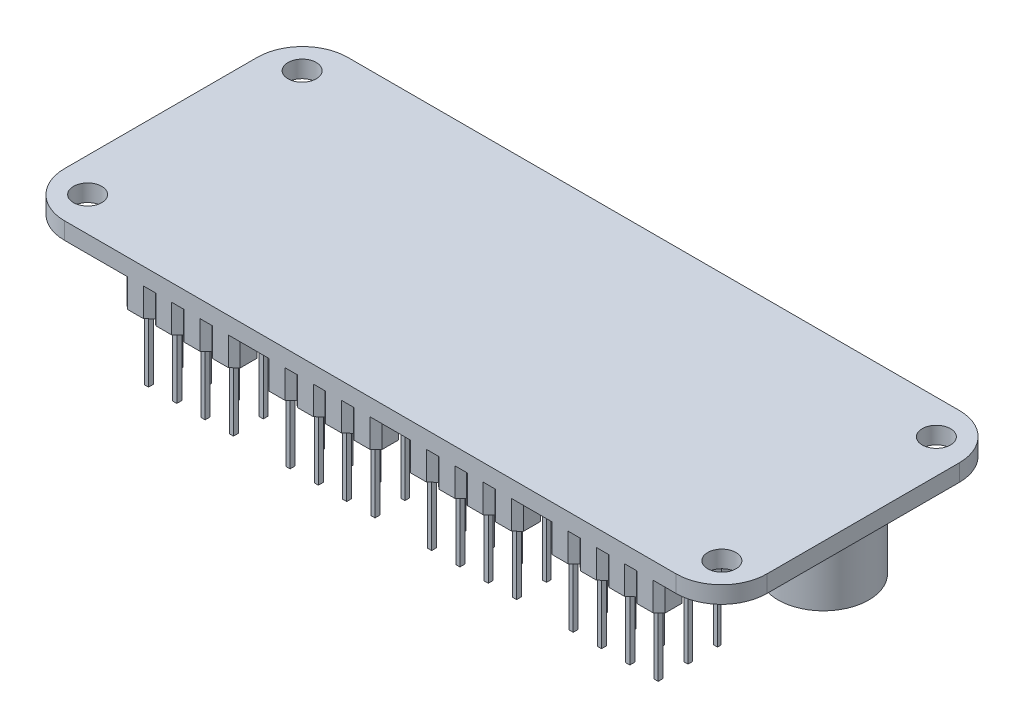
from build123d import *

# Parameters (mm, degrees)
CROQUIS1_W                  = 62
CROQUIS1_H                  = 25
SALIENTE_EXTRUIR1_DEPTH     = 1.5
REDONDEO1_R                 = 4
CROQUIS2_R                  = 1.25
CORTAR_EXTRUIR1_DEPTH       = 10
CROQUIS3_R                  = 4
SALIENTE_EXTRUIR2_DEPTH     = 13
SALIENTE_EXTRUIR3_DEPTH     = 2.5
CROQUIS5_W                  = 0.360808051
CROQUIS5_H                  = 0.305625598
CROQUIS5_H_2                = 0.406989353
CROQUIS5_H_3                = 0.438823002
SALIENTE_EXTRUIR4_DEPTH     = 6
MATRIZL1_COUNT              = 4
MATRIZL1_PITCH              = 2.5
MATRIZL2_COUNT              = 4
MATRIZL2_PITCH              = 12.5
MATRIZL2_COPY_1_DEPTH       = 2.5
MATRIZL2_COPY_2_DEPTH       = 2.5
MATRIZL2_COPY_3_DEPTH       = 2.5
MATRIZL2_COPY_4_DEPTH       = 2.5
MATRIZL2_COPY_5_DEPTH       = 2.5
MATRIZL2_COPY_6_DEPTH       = 2.5
MATRIZL2_COPY_7_DEPTH       = 2.5
MATRIZL2_COPY_8_DEPTH       = 2.5
MATRIZL2_COPY_9_DEPTH       = 2.5
MATRIZL2_COPY_10_SKETCH_W   = 0.360808051
MATRIZL2_COPY_10_SKETCH_H   = 0.305625598
MATRIZL2_COPY_10_SKETCH_H_2 = 0.406989353
MATRIZL2_COPY_10_SKETCH_H_3 = 0.438823002
MATRIZL2_COPY_10_DEPTH      = 6
MATRIZL2_COPY_11_SKETCH_W   = 0.360808051
MATRIZL2_COPY_11_SKETCH_H   = 0.305625598
MATRIZL2_COPY_11_SKETCH_H_2 = 0.406989353
MATRIZL2_COPY_11_SKETCH_H_3 = 0.438823002
MATRIZL2_COPY_11_DEPTH      = 6
MATRIZL2_COPY_12_SKETCH_W   = 0.360808051
MATRIZL2_COPY_12_SKETCH_H   = 0.305625598
MATRIZL2_COPY_12_SKETCH_H_2 = 0.406989353
MATRIZL2_COPY_12_SKETCH_H_3 = 0.438823002
MATRIZL2_COPY_12_DEPTH      = 6
MATRIZL2_COPY_13_SKETCH_W   = 0.360808051
MATRIZL2_COPY_13_SKETCH_H   = 0.305625598
MATRIZL2_COPY_13_SKETCH_H_2 = 0.406989353
MATRIZL2_COPY_13_SKETCH_H_3 = 0.438823002
MATRIZL2_COPY_13_DEPTH      = 6
MATRIZL2_COPY_14_SKETCH_W   = 0.360808051
MATRIZL2_COPY_14_SKETCH_H   = 0.305625598
MATRIZL2_COPY_14_SKETCH_H_2 = 0.406989353
MATRIZL2_COPY_14_SKETCH_H_3 = 0.438823002
MATRIZL2_COPY_14_DEPTH      = 6
MATRIZL2_COPY_15_SKETCH_W   = 0.360808051
MATRIZL2_COPY_15_SKETCH_H   = 0.305625598
MATRIZL2_COPY_15_SKETCH_H_2 = 0.406989353
MATRIZL2_COPY_15_SKETCH_H_3 = 0.438823002
MATRIZL2_COPY_15_DEPTH      = 6
MATRIZL2_COPY_16_SKETCH_W   = 0.360808051
MATRIZL2_COPY_16_SKETCH_H   = 0.305625598
MATRIZL2_COPY_16_SKETCH_H_2 = 0.406989353
MATRIZL2_COPY_16_SKETCH_H_3 = 0.438823002
MATRIZL2_COPY_16_DEPTH      = 6
MATRIZL2_COPY_17_SKETCH_W   = 0.360808051
MATRIZL2_COPY_17_SKETCH_H   = 0.305625598
MATRIZL2_COPY_17_SKETCH_H_2 = 0.406989353
MATRIZL2_COPY_17_SKETCH_H_3 = 0.438823002
MATRIZL2_COPY_17_DEPTH      = 6
MATRIZL2_COPY_18_SKETCH_W   = 0.360808051
MATRIZL2_COPY_18_SKETCH_H   = 0.305625598
MATRIZL2_COPY_18_SKETCH_H_2 = 0.406989353
MATRIZL2_COPY_18_SKETCH_H_3 = 0.438823002
MATRIZL2_COPY_18_DEPTH      = 6


with BuildPart() as part:
    # Croquis1 → Saliente-Extruir1 (new body)
    with BuildSketch(Plane(origin=(0, 0, 0), x_dir=(1, 0, 0), z_dir=(0, 1, 0))):
        Rectangle(CROQUIS1_W, CROQUIS1_H)
    extrude(amount=SALIENTE_EXTRUIR1_DEPTH)

    # Redondeo1
    redondeo1_edges = [part.edges().sort_by_distance(p)[0] for p in [
        (31, 0.75, 12.5),
        (-31, 0.75, 12.5),
        (-31, 0.75, -12.5),
        (31, 0.75, -12.5),
    ]]
    fillet(redondeo1_edges, radius=REDONDEO1_R)

    # Croquis2 → Cortar-Extruir1 (cut)
    with BuildSketch(Plane(origin=(0, 1.5, 0), x_dir=(1, 0, 0), z_dir=(0, 1, 0))):
        with Locations((-28, 9.47)):
            Circle(CROQUIS2_R)
        with Locations((28, 9.47)):
            Circle(CROQUIS2_R)
        with Locations((28, -9.47)):
            Circle(CROQUIS2_R)
        with Locations((-28, -9.47)):
            Circle(CROQUIS2_R)
    extrude(amount=-CORTAR_EXTRUIR1_DEPTH, mode=Mode.SUBTRACT)

    # Croquis3 → Saliente-Extruir2 (add)
    with BuildSketch(Plane.XZ):
        with Locations((19, -8.5)):
            Circle(CROQUIS3_R)
    extrude(amount=SALIENTE_EXTRUIR2_DEPTH)

    # Croquis4 → Saliente-Extruir3 (add)
    with BuildSketch(Plane.XZ):
        Polygon((24.951236273, 5), (23.548763727, 5), (23, 5.501296545), (23, 6.998703455), (23.548763727, 7.5), (23, 8.001296545), (23, 9.498703455), (23.548763727, 10), (23, 10.501296545), (23, 11.998703455), (23.548763727, 12.5), (24.951236273, 12.5), (25.5, 11.998703455), (25.5, 10.501296545), (24.951236273, 10), (25.5, 9.498703455), (25.5, 8.001296545), (24.951236273, 7.5), (25.5, 6.998703455), (25.5, 5.501296545), align=None)
    saliente_extruir3 = extrude(amount=SALIENTE_EXTRUIR3_DEPTH)

    # Croquis5 → Saliente-Extruir4 (add)
    with BuildSketch(Plane.XZ.offset(2.5)):
        with Locations((24.238999637, 6.119725435)):
            Rectangle(CROQUIS5_W, CROQUIS5_H)
        with Locations((24.238999637, 8.674638073)):
            Rectangle(CROQUIS5_W, CROQUIS5_H_2)
        with Locations((24.238999637, 11.296149412)):
            Rectangle(CROQUIS5_W, CROQUIS5_H_3)
    saliente_extruir4 = extrude(amount=SALIENTE_EXTRUIR4_DEPTH)

    # MatrizL1: Saliente-Extruir3, Saliente-Extruir4 ×4
    with Locations(*[(-i * MATRIZL1_PITCH, 0, 0) for i in range(1, MATRIZL1_COUNT)]):
        add(saliente_extruir3)
        add(saliente_extruir4)

    # MatrizL2: Saliente-Extruir3, Saliente-Extruir4 ×4
    with Locations(*[(-i * MATRIZL2_PITCH, 0, 0) for i in range(1, MATRIZL2_COUNT)]):
        add(saliente_extruir3)
        add(saliente_extruir4)

    # MatrizL2 copy 1 sketch → MatrizL2 copy 1 (add)
    with BuildSketch(Plane(origin=(-15, 0, 0), x_dir=(1, 0, 0), z_dir=(0, -1, 0))):
        Polygon((24.951236273, 5), (23.548763727, 5), (23, 5.501296545), (23, 6.998703455), (23.548763727, 7.5), (23, 8.001296545), (23, 9.498703455), (23.548763727, 10), (23, 10.501296545), (23, 11.998703455), (23.548763727, 12.5), (24.951236273, 12.5), (25.5, 11.998703455), (25.5, 10.501296545), (24.951236273, 10), (25.5, 9.498703455), (25.5, 8.001296545), (24.951236273, 7.5), (25.5, 6.998703455), (25.5, 5.501296545), align=None)
    extrude(amount=MATRIZL2_COPY_1_DEPTH)

    # MatrizL2 copy 2 sketch → MatrizL2 copy 2 (add)
    with BuildSketch(Plane(origin=(-27.5, 0, 0), x_dir=(1, 0, 0), z_dir=(0, -1, 0))):
        Polygon((24.951236273, 5), (23.548763727, 5), (23, 5.501296545), (23, 6.998703455), (23.548763727, 7.5), (23, 8.001296545), (23, 9.498703455), (23.548763727, 10), (23, 10.501296545), (23, 11.998703455), (23.548763727, 12.5), (24.951236273, 12.5), (25.5, 11.998703455), (25.5, 10.501296545), (24.951236273, 10), (25.5, 9.498703455), (25.5, 8.001296545), (24.951236273, 7.5), (25.5, 6.998703455), (25.5, 5.501296545), align=None)
    extrude(amount=MATRIZL2_COPY_2_DEPTH)

    # MatrizL2 copy 3 sketch → MatrizL2 copy 3 (add)
    with BuildSketch(Plane(origin=(-40, 0, 0), x_dir=(1, 0, 0), z_dir=(0, -1, 0))):
        Polygon((24.951236273, 5), (23.548763727, 5), (23, 5.501296545), (23, 6.998703455), (23.548763727, 7.5), (23, 8.001296545), (23, 9.498703455), (23.548763727, 10), (23, 10.501296545), (23, 11.998703455), (23.548763727, 12.5), (24.951236273, 12.5), (25.5, 11.998703455), (25.5, 10.501296545), (24.951236273, 10), (25.5, 9.498703455), (25.5, 8.001296545), (24.951236273, 7.5), (25.5, 6.998703455), (25.5, 5.501296545), align=None)
    extrude(amount=MATRIZL2_COPY_3_DEPTH)

    # MatrizL2 copy 4 sketch → MatrizL2 copy 4 (add)
    with BuildSketch(Plane(origin=(-17.5, 0, 0), x_dir=(1, 0, 0), z_dir=(0, -1, 0))):
        Polygon((24.951236273, 5), (23.548763727, 5), (23, 5.501296545), (23, 6.998703455), (23.548763727, 7.5), (23, 8.001296545), (23, 9.498703455), (23.548763727, 10), (23, 10.501296545), (23, 11.998703455), (23.548763727, 12.5), (24.951236273, 12.5), (25.5, 11.998703455), (25.5, 10.501296545), (24.951236273, 10), (25.5, 9.498703455), (25.5, 8.001296545), (24.951236273, 7.5), (25.5, 6.998703455), (25.5, 5.501296545), align=None)
    extrude(amount=MATRIZL2_COPY_4_DEPTH)

    # MatrizL2 copy 5 sketch → MatrizL2 copy 5 (add)
    with BuildSketch(Plane(origin=(-30, 0, 0), x_dir=(1, 0, 0), z_dir=(0, -1, 0))):
        Polygon((24.951236273, 5), (23.548763727, 5), (23, 5.501296545), (23, 6.998703455), (23.548763727, 7.5), (23, 8.001296545), (23, 9.498703455), (23.548763727, 10), (23, 10.501296545), (23, 11.998703455), (23.548763727, 12.5), (24.951236273, 12.5), (25.5, 11.998703455), (25.5, 10.501296545), (24.951236273, 10), (25.5, 9.498703455), (25.5, 8.001296545), (24.951236273, 7.5), (25.5, 6.998703455), (25.5, 5.501296545), align=None)
    extrude(amount=MATRIZL2_COPY_5_DEPTH)

    # MatrizL2 copy 6 sketch → MatrizL2 copy 6 (add)
    with BuildSketch(Plane(origin=(-42.5, 0, 0), x_dir=(1, 0, 0), z_dir=(0, -1, 0))):
        Polygon((24.951236273, 5), (23.548763727, 5), (23, 5.501296545), (23, 6.998703455), (23.548763727, 7.5), (23, 8.001296545), (23, 9.498703455), (23.548763727, 10), (23, 10.501296545), (23, 11.998703455), (23.548763727, 12.5), (24.951236273, 12.5), (25.5, 11.998703455), (25.5, 10.501296545), (24.951236273, 10), (25.5, 9.498703455), (25.5, 8.001296545), (24.951236273, 7.5), (25.5, 6.998703455), (25.5, 5.501296545), align=None)
    extrude(amount=MATRIZL2_COPY_6_DEPTH)

    # MatrizL2 copy 7 sketch → MatrizL2 copy 7 (add)
    with BuildSketch(Plane(origin=(-20, 0, 0), x_dir=(1, 0, 0), z_dir=(0, -1, 0))):
        Polygon((24.951236273, 5), (23.548763727, 5), (23, 5.501296545), (23, 6.998703455), (23.548763727, 7.5), (23, 8.001296545), (23, 9.498703455), (23.548763727, 10), (23, 10.501296545), (23, 11.998703455), (23.548763727, 12.5), (24.951236273, 12.5), (25.5, 11.998703455), (25.5, 10.501296545), (24.951236273, 10), (25.5, 9.498703455), (25.5, 8.001296545), (24.951236273, 7.5), (25.5, 6.998703455), (25.5, 5.501296545), align=None)
    extrude(amount=MATRIZL2_COPY_7_DEPTH)

    # MatrizL2 copy 8 sketch → MatrizL2 copy 8 (add)
    with BuildSketch(Plane(origin=(-32.5, 0, 0), x_dir=(1, 0, 0), z_dir=(0, -1, 0))):
        Polygon((24.951236273, 5), (23.548763727, 5), (23, 5.501296545), (23, 6.998703455), (23.548763727, 7.5), (23, 8.001296545), (23, 9.498703455), (23.548763727, 10), (23, 10.501296545), (23, 11.998703455), (23.548763727, 12.5), (24.951236273, 12.5), (25.5, 11.998703455), (25.5, 10.501296545), (24.951236273, 10), (25.5, 9.498703455), (25.5, 8.001296545), (24.951236273, 7.5), (25.5, 6.998703455), (25.5, 5.501296545), align=None)
    extrude(amount=MATRIZL2_COPY_8_DEPTH)

    # MatrizL2 copy 9 sketch → MatrizL2 copy 9 (add)
    with BuildSketch(Plane(origin=(-45, 0, 0), x_dir=(1, 0, 0), z_dir=(0, -1, 0))):
        Polygon((24.951236273, 5), (23.548763727, 5), (23, 5.501296545), (23, 6.998703455), (23.548763727, 7.5), (23, 8.001296545), (23, 9.498703455), (23.548763727, 10), (23, 10.501296545), (23, 11.998703455), (23.548763727, 12.5), (24.951236273, 12.5), (25.5, 11.998703455), (25.5, 10.501296545), (24.951236273, 10), (25.5, 9.498703455), (25.5, 8.001296545), (24.951236273, 7.5), (25.5, 6.998703455), (25.5, 5.501296545), align=None)
    extrude(amount=MATRIZL2_COPY_9_DEPTH)

    # MatrizL2 copy 10 sketch → MatrizL2 copy 10 (add)
    with BuildSketch(Plane(origin=(-15, -2.5, 0), x_dir=(1, 0, 0), z_dir=(0, -1, 0))):
        with Locations((24.238999637, 6.119725435)):
            Rectangle(MATRIZL2_COPY_10_SKETCH_W, MATRIZL2_COPY_10_SKETCH_H)
        with Locations((24.238999637, 8.674638073)):
            Rectangle(MATRIZL2_COPY_10_SKETCH_W, MATRIZL2_COPY_10_SKETCH_H_2)
        with Locations((24.238999637, 11.296149412)):
            Rectangle(MATRIZL2_COPY_10_SKETCH_W, MATRIZL2_COPY_10_SKETCH_H_3)
    extrude(amount=MATRIZL2_COPY_10_DEPTH)

    # MatrizL2 copy 11 sketch → MatrizL2 copy 11 (add)
    with BuildSketch(Plane(origin=(-27.5, -2.5, 0), x_dir=(1, 0, 0), z_dir=(0, -1, 0))):
        with Locations((24.238999637, 6.119725435)):
            Rectangle(MATRIZL2_COPY_11_SKETCH_W, MATRIZL2_COPY_11_SKETCH_H)
        with Locations((24.238999637, 8.674638073)):
            Rectangle(MATRIZL2_COPY_11_SKETCH_W, MATRIZL2_COPY_11_SKETCH_H_2)
        with Locations((24.238999637, 11.296149412)):
            Rectangle(MATRIZL2_COPY_11_SKETCH_W, MATRIZL2_COPY_11_SKETCH_H_3)
    extrude(amount=MATRIZL2_COPY_11_DEPTH)

    # MatrizL2 copy 12 sketch → MatrizL2 copy 12 (add)
    with BuildSketch(Plane(origin=(-40, -2.5, 0), x_dir=(1, 0, 0), z_dir=(0, -1, 0))):
        with Locations((24.238999637, 6.119725435)):
            Rectangle(MATRIZL2_COPY_12_SKETCH_W, MATRIZL2_COPY_12_SKETCH_H)
        with Locations((24.238999637, 8.674638073)):
            Rectangle(MATRIZL2_COPY_12_SKETCH_W, MATRIZL2_COPY_12_SKETCH_H_2)
        with Locations((24.238999637, 11.296149412)):
            Rectangle(MATRIZL2_COPY_12_SKETCH_W, MATRIZL2_COPY_12_SKETCH_H_3)
    extrude(amount=MATRIZL2_COPY_12_DEPTH)

    # MatrizL2 copy 13 sketch → MatrizL2 copy 13 (add)
    with BuildSketch(Plane(origin=(-17.5, -2.5, 0), x_dir=(1, 0, 0), z_dir=(0, -1, 0))):
        with Locations((24.238999637, 6.119725435)):
            Rectangle(MATRIZL2_COPY_13_SKETCH_W, MATRIZL2_COPY_13_SKETCH_H)
        with Locations((24.238999637, 8.674638073)):
            Rectangle(MATRIZL2_COPY_13_SKETCH_W, MATRIZL2_COPY_13_SKETCH_H_2)
        with Locations((24.238999637, 11.296149412)):
            Rectangle(MATRIZL2_COPY_13_SKETCH_W, MATRIZL2_COPY_13_SKETCH_H_3)
    extrude(amount=MATRIZL2_COPY_13_DEPTH)

    # MatrizL2 copy 14 sketch → MatrizL2 copy 14 (add)
    with BuildSketch(Plane(origin=(-30, -2.5, 0), x_dir=(1, 0, 0), z_dir=(0, -1, 0))):
        with Locations((24.238999637, 6.119725435)):
            Rectangle(MATRIZL2_COPY_14_SKETCH_W, MATRIZL2_COPY_14_SKETCH_H)
        with Locations((24.238999637, 8.674638073)):
            Rectangle(MATRIZL2_COPY_14_SKETCH_W, MATRIZL2_COPY_14_SKETCH_H_2)
        with Locations((24.238999637, 11.296149412)):
            Rectangle(MATRIZL2_COPY_14_SKETCH_W, MATRIZL2_COPY_14_SKETCH_H_3)
    extrude(amount=MATRIZL2_COPY_14_DEPTH)

    # MatrizL2 copy 15 sketch → MatrizL2 copy 15 (add)
    with BuildSketch(Plane(origin=(-42.5, -2.5, 0), x_dir=(1, 0, 0), z_dir=(0, -1, 0))):
        with Locations((24.238999637, 6.119725435)):
            Rectangle(MATRIZL2_COPY_15_SKETCH_W, MATRIZL2_COPY_15_SKETCH_H)
        with Locations((24.238999637, 8.674638073)):
            Rectangle(MATRIZL2_COPY_15_SKETCH_W, MATRIZL2_COPY_15_SKETCH_H_2)
        with Locations((24.238999637, 11.296149412)):
            Rectangle(MATRIZL2_COPY_15_SKETCH_W, MATRIZL2_COPY_15_SKETCH_H_3)
    extrude(amount=MATRIZL2_COPY_15_DEPTH)

    # MatrizL2 copy 16 sketch → MatrizL2 copy 16 (add)
    with BuildSketch(Plane(origin=(-20, -2.5, 0), x_dir=(1, 0, 0), z_dir=(0, -1, 0))):
        with Locations((24.238999637, 6.119725435)):
            Rectangle(MATRIZL2_COPY_16_SKETCH_W, MATRIZL2_COPY_16_SKETCH_H)
        with Locations((24.238999637, 8.674638073)):
            Rectangle(MATRIZL2_COPY_16_SKETCH_W, MATRIZL2_COPY_16_SKETCH_H_2)
        with Locations((24.238999637, 11.296149412)):
            Rectangle(MATRIZL2_COPY_16_SKETCH_W, MATRIZL2_COPY_16_SKETCH_H_3)
    extrude(amount=MATRIZL2_COPY_16_DEPTH)

    # MatrizL2 copy 17 sketch → MatrizL2 copy 17 (add)
    with BuildSketch(Plane(origin=(-32.5, -2.5, 0), x_dir=(1, 0, 0), z_dir=(0, -1, 0))):
        with Locations((24.238999637, 6.119725435)):
            Rectangle(MATRIZL2_COPY_17_SKETCH_W, MATRIZL2_COPY_17_SKETCH_H)
        with Locations((24.238999637, 8.674638073)):
            Rectangle(MATRIZL2_COPY_17_SKETCH_W, MATRIZL2_COPY_17_SKETCH_H_2)
        with Locations((24.238999637, 11.296149412)):
            Rectangle(MATRIZL2_COPY_17_SKETCH_W, MATRIZL2_COPY_17_SKETCH_H_3)
    extrude(amount=MATRIZL2_COPY_17_DEPTH)

    # MatrizL2 copy 18 sketch → MatrizL2 copy 18 (add)
    with BuildSketch(Plane(origin=(-45, -2.5, 0), x_dir=(1, 0, 0), z_dir=(0, -1, 0))):
        with Locations((24.238999637, 6.119725435)):
            Rectangle(MATRIZL2_COPY_18_SKETCH_W, MATRIZL2_COPY_18_SKETCH_H)
        with Locations((24.238999637, 8.674638073)):
            Rectangle(MATRIZL2_COPY_18_SKETCH_W, MATRIZL2_COPY_18_SKETCH_H_2)
        with Locations((24.238999637, 11.296149412)):
            Rectangle(MATRIZL2_COPY_18_SKETCH_W, MATRIZL2_COPY_18_SKETCH_H_3)
    extrude(amount=MATRIZL2_COPY_18_DEPTH)


solid = part.part
